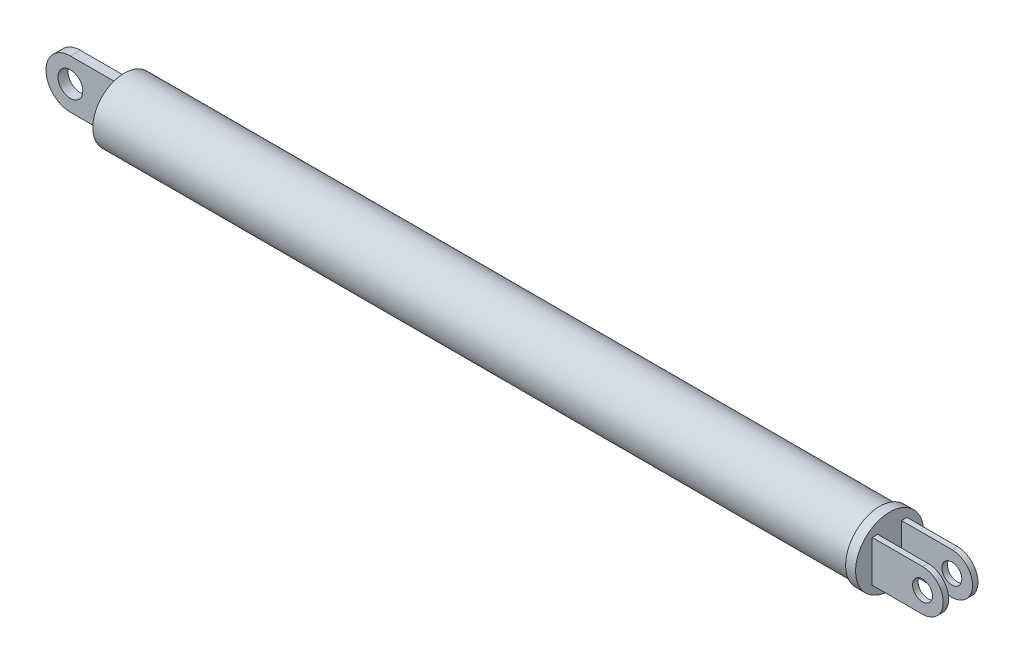
from build123d import *

# Parameters (mm, degrees)
SKETCH1_R               = 12.7
EXTRUDE1_DEPTH          = 304
SKETCH2_R               = 5
EXTRUDE2_DEPTH          = 2
SKETCH3_R               = 13.7
EXTRUDE3_DEPTH          = 4
SKETCH4_R               = 4
EXTRUDE4_DEPTH          = 7
SKETCH5_W               = 51.727972269
SKETCH5_H               = 9.602426348
CUT_EXTRUDE1_DEPTH      = 14.7
CUT_EXTRUDE1_DEPTH_BACK = 14.7


with BuildPart() as part:
    # Sketch1 → Extrude1 (new body)
    with BuildSketch(Plane(origin=(0, 0, 0), x_dir=(0, 0, -1), z_dir=(1, 0, 0))):
        Circle(SKETCH1_R)
    extrude(amount=EXTRUDE1_DEPTH)

    # Sketch2 → Extrude2 (add, symmetric)
    with BuildSketch(Plane.XY):
        with BuildLine():
            Line((0, 9.805687548), (-19.733094472, 9.805687548))
            ThreePointArc((-19.733094472, 9.805687548), (-29.53878202, 0), (-19.733094472, -9.805687548))
            Line((-19.733094472, -9.805687548), (0, -9.805687548))
            Line((0, -9.805687548), (0, 9.805687548))
        make_face()
        with Locations((-19.733094472, 0)):
            Circle(SKETCH2_R, mode=Mode.SUBTRACT)
    extrude(amount=EXTRUDE2_DEPTH, both=True)

    # Sketch3 → Extrude3 (add)
    with BuildSketch(Plane(origin=(304, 0, 0), x_dir=(0, 0, -1), z_dir=(1, 0, 0))):
        Circle(SKETCH3_R)
    extrude(amount=EXTRUDE3_DEPTH)

    # Sketch4 → Extrude4 (add, symmetric)
    with BuildSketch(Plane.XY):
        with BuildLine():
            Line((308, 8.324679236), (328.238920727, 8.324679236))
            ThreePointArc((328.238920727, 8.324679236), (336.563599963, 0), (328.238920727, -8.324679236))
            Line((328.238920727, -8.324679236), (308, -8.324679236))
            Line((308, -8.324679236), (308, 8.324679236))
        make_face()
        with Locations((328.238920727, 0)):
            Circle(SKETCH4_R, mode=Mode.SUBTRACT)
    extrude(amount=EXTRUDE4_DEPTH, both=True)

    # Sketch5 → Cut-Extrude1 (cut, two sides)
    with BuildSketch(Plane(origin=(0, 0, 0), x_dir=(1, 0, 0), z_dir=(0, 1, 0))) as cut_extrude1_sk:
        with Locations((333.863986135, 0)):
            Rectangle(SKETCH5_W, SKETCH5_H)
    extrude(amount=CUT_EXTRUDE1_DEPTH, mode=Mode.SUBTRACT)
    extrude(cut_extrude1_sk.sketch, amount=-CUT_EXTRUDE1_DEPTH_BACK, mode=Mode.SUBTRACT)


solid = part.part
